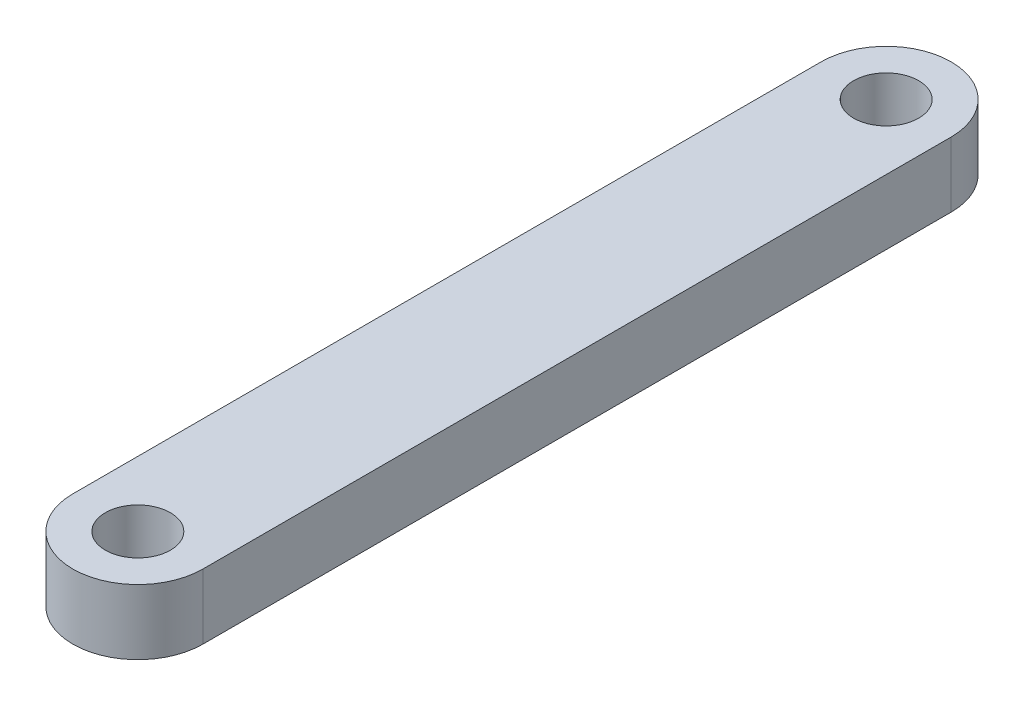
from build123d import *

# Parameters (mm, degrees)
SKETCH1_R           = 2
BOSS_EXTRUDE1_DEPTH = 4


with BuildPart() as part:
    # Sketch1 → Boss-Extrude1 (new body)
    with BuildSketch(Plane(origin=(0, 0, 0), x_dir=(1, 0, 0), z_dir=(0, 1, 0))):
        with BuildLine():
            Line((4, 23), (4, -23))
            ThreePointArc((4, -23), (0, -27), (-4, -23))
            Line((-4, -23), (-4, 23))
            ThreePointArc((-4, 23), (0, 27), (4, 23))
        make_face()
        with Locations((0, 23)):
            Circle(SKETCH1_R, mode=Mode.SUBTRACT)
        with Locations((0, -23)):
            Circle(SKETCH1_R, mode=Mode.SUBTRACT)
    extrude(amount=BOSS_EXTRUDE1_DEPTH)


solid = part.part
